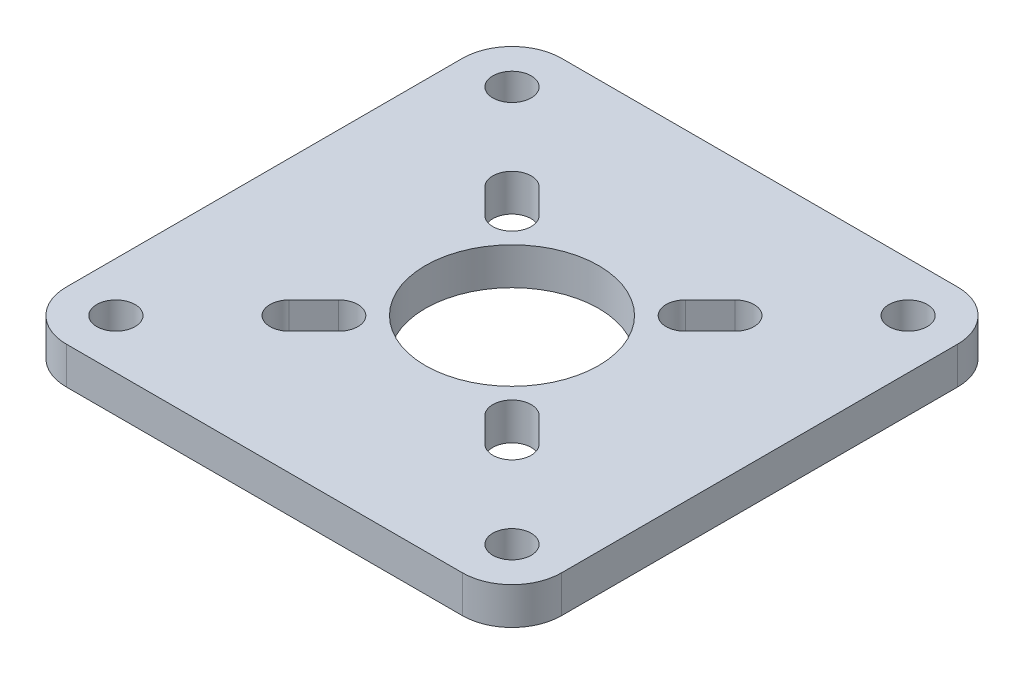
from build123d import *

# Parameters (mm, degrees)
SKETCH1_W           = 40
SKETCH1_H           = 40
BOSS_EXTRUDE1_DEPTH = 1.5
FILLET1_R           = 4
SKETCH3_R           = 7
SKETCH3_R_2         = 1.55
CUT_EXTRUDE2_DEPTH  = 3


with BuildPart() as part:
    # Sketch1 → Boss-Extrude1 (new body, symmetric)
    with BuildSketch(Plane(origin=(0, 0, 0), x_dir=(1, 0, 0), z_dir=(0, 1, 0))):
        Rectangle(SKETCH1_W, SKETCH1_H)
    extrude(amount=BOSS_EXTRUDE1_DEPTH, both=True)

    # Fillet1
    fillet1_edges = [part.edges().sort_by_distance(p)[0] for p in [
        (20, 0, 20),
        (-20, 0, 20),
        (-20, 0, -20),
        (20, 0, -20),
    ]]
    fillet(fillet1_edges, radius=FILLET1_R)

    # Sketch3 → Cut-Extrude2 (cut)
    with BuildSketch(Plane(origin=(0, 1.5, 0), x_dir=(1, 0, 0), z_dir=(0, 1, 0))):
        Circle(SKETCH3_R)
        with BuildLine():
            Line((5.903984489, -8.096015511), (7.903984489, -10.096015511))
            ThreePointArc((7.903984489, -10.096015511), (10.096015511, -10.096015511), (10.096015511, -7.903984489))
            Line((10.096015511, -7.903984489), (8.096015511, -5.903984489))
            ThreePointArc((8.096015511, -5.903984489), (5.903984489, -5.903984489), (5.903984489, -8.096015511))
        make_face()
        with Locations((16, -16)):
            Circle(SKETCH3_R_2)
        with BuildLine():
            ThreePointArc((-7.903984489, -10.096015511), (-10.096015511, -10.096015511), (-10.096015511, -7.903984489))
            Line((-10.096015511, -7.903984489), (-8.096015511, -5.903984489))
            ThreePointArc((-8.096015511, -5.903984489), (-5.903984489, -5.903984489), (-5.903984489, -8.096015511))
            Line((-5.903984489, -8.096015511), (-7.903984489, -10.096015511))
        make_face()
        with BuildLine():
            Line((-5.903984489, 8.096015511), (-7.903984489, 10.096015511))
            ThreePointArc((-7.903984489, 10.096015511), (-10.096015511, 10.096015511), (-10.096015511, 7.903984489))
            Line((-10.096015511, 7.903984489), (-8.096015511, 5.903984489))
            ThreePointArc((-8.096015511, 5.903984489), (-5.903984489, 5.903984489), (-5.903984489, 8.096015511))
        make_face()
        with Locations((-16, 16)):
            Circle(SKETCH3_R_2)
        with BuildLine():
            ThreePointArc((7.903984489, 10.096015511), (10.096015511, 10.096015511), (10.096015511, 7.903984489))
            Line((10.096015511, 7.903984489), (8.096015511, 5.903984489))
            ThreePointArc((8.096015511, 5.903984489), (5.903984489, 5.903984489), (5.903984489, 8.096015511))
            Line((5.903984489, 8.096015511), (7.903984489, 10.096015511))
        make_face()
        with Locations((16, 16)):
            Circle(SKETCH3_R_2)
        with Locations((-16, -16)):
            Circle(SKETCH3_R_2)
        with BuildLine():
            ThreePointArc((-6, 5.815728072), (-5.903984489, 5.903984489), (-5.815728072, 6))
            Line((-5.815728072, 6), (-6, 6))
            Line((-6, 6), (-6, 5.815728072))
        make_face()
        with BuildLine():
            Line((-6, -6), (-5.815728072, -6))
            ThreePointArc((-5.815728072, -6), (-5.903984489, -5.903984489), (-6, -5.815728072))
            Line((-6, -5.815728072), (-6, -6))
        make_face()
        with BuildLine():
            Line((6, -6), (6, -5.815728072))
            ThreePointArc((6, -5.815728072), (5.903984489, -5.903984489), (5.815728072, -6))
            Line((5.815728072, -6), (6, -6))
        make_face()
        with BuildLine():
            ThreePointArc((5.815728072, 6), (5.903984489, 5.903984489), (6, 5.815728072))
            Line((6, 5.815728072), (6, 6))
            Line((6, 6), (5.815728072, 6))
        make_face()
        with BuildLine():
            ThreePointArc((-6, 3.605551275), (-7, 0), (-6, -3.605551275))
            Line((-6, -3.605551275), (-6, 3.605551275))
        make_face()
        with BuildLine():
            Line((-3.605551275, 6), (3.605551275, 6))
            ThreePointArc((3.605551275, 6), (0, 7), (-3.605551275, 6))
        make_face()
        with BuildLine():
            Line((6, 3.605551275), (6, -3.605551275))
            ThreePointArc((6, -3.605551275), (6.745368782, -1.870828693), (7, 0))
            ThreePointArc((7, 0), (6.745368782, 1.870828693), (6, 3.605551275))
        make_face()
        with BuildLine():
            ThreePointArc((-3.605551275, -6), (0, -7), (3.605551275, -6))
            Line((3.605551275, -6), (-3.605551275, -6))
        make_face()
    extrude(amount=-CUT_EXTRUDE2_DEPTH, mode=Mode.SUBTRACT)


solid = part.part
